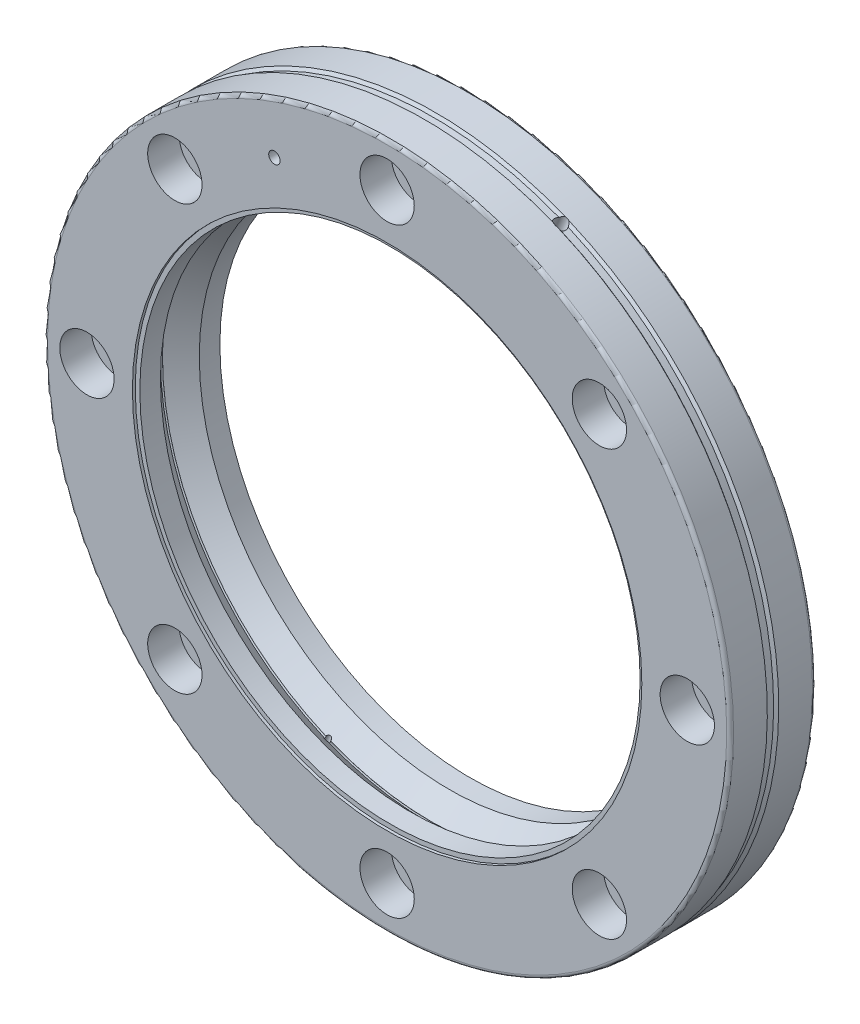
from build123d import *

# Parameters (mm, degrees)
SKETCH_1_R                     = 60
SKETCH_1_R_2                   = 43.75
EXTRUDE_1_DEPTH                = 7.5
FILLET_1_R                     = 0.6
HOLE_WIZARD_M1_6_1_D           = 5.6
HOLE_WIZARD_M1_6_1_CBORE_D     = 9.5
HOLE_WIZARD_M1_6_1_CBORE_DEPTH = 5.5
PATTERN_CIRCULAR_1_COUNT       = 8
CUT_EXTRUDE_START              = 60
SKETCH_7_R                     = 1.05
CUT_EXTRUDE_1_DEPTH            = 5
SKETCH_8_R                     = 0.5
CUT_EXTRUDE_2_DEPTH            = 15
PATTERN_CIRCULAR_2_COUNT       = 2
SKETCH_9_R                     = 44.55
CUT_EXTRUDE_3_DEPTH            = 0.5


with BuildPart() as part:
    # 草图1 → 凸台-拉伸1 (new, symmetric)
    with BuildSketch(Plane.XY):
        Circle(SKETCH_1_R)
        Circle(SKETCH_1_R_2, mode=Mode.SUBTRACT)
    extrude(amount=EXTRUDE_1_DEPTH, both=True)

    # 草图2 → 切除-旋转1 (revolve, cut)
    with BuildSketch(Plane(origin=(0, 0, 0), x_dir=(0, 0, -1), z_dir=(1, 0, 0))):
        with BuildLine():
            Line((-3.535533906, 43.61), (-0.176776695, 46.968757211))
            ThreePointArc((-0.176776695, 46.968757211), (0, 47.395533906), (0.176776695, 46.968757211))
            Line((0.176776695, 46.968757211), (3.535533906, 43.61))
            Line((3.535533906, 43.61), (-3.535533906, 43.61))
        make_face()
        Polygon((-1, 60), (1, 60), (0.6, 59.5), (-0.6, 59.5), align=None)
    revolve(axis=Axis((0, 0, 12.553599724), (0, 0, -1)), mode=Mode.SUBTRACT)

    # 圆角1
    fillet_1_edges = [part.edges().sort_by_distance(p)[0] for p in [
        (-60, 0, -7.5),
        (-60, 0, 7.5),
    ]]
    fillet(fillet_1_edges, radius=FILLET_1_R)

    # M1.6 六角头螺栓的柱形沉头孔1 (through all)
    with Locations(Plane.XY.offset(7.5)):
        with Locations((0, 52.5)):
            hole_wizard_m1_6_1 = CounterBoreHole(HOLE_WIZARD_M1_6_1_D / 2, HOLE_WIZARD_M1_6_1_CBORE_D / 2, HOLE_WIZARD_M1_6_1_CBORE_DEPTH)

    # 阵列(圆周)1: M1.6 六角头螺栓的柱形沉头孔1 ×8 about axis
    pattern_circular_1_axis = Axis((0, 0, 7.5), (0, 0, -1))
    for i in range(1, PATTERN_CIRCULAR_1_COUNT):
        add(hole_wizard_m1_6_1.rotate(pattern_circular_1_axis, i * 360 / PATTERN_CIRCULAR_1_COUNT), mode=Mode.SUBTRACT)

    # 草图7 → 切除-拉伸1 (cut)
    with BuildSketch(Plane(origin=(0, 0, 0), x_dir=(0, 0, -1), z_dir=(0.3826834323650906, 0.9238795325112865, 0)).offset(CUT_EXTRUDE_START)):
        Circle(SKETCH_7_R)
    cut_extrude_1 = extrude(amount=-CUT_EXTRUDE_1_DEPTH, mode=Mode.SUBTRACT)

    # 草图8 → 切除-拉伸2 (cut)
    with BuildSketch(Plane(origin=(21.04758878, 50.813374288, 0), x_dir=(0.9238795325112864, -0.38268343236509067, 0), z_dir=(0.38268343236509067, 0.9238795325112864, 0))):
        Circle(SKETCH_8_R)
    cut_extrude_2 = extrude(amount=-CUT_EXTRUDE_2_DEPTH, mode=Mode.SUBTRACT)

    # 阵列(圆周)2: 切除-拉伸1, 切除-拉伸2 ×2 about axis
    pattern_circular_2_axis = Axis((0, 0, 7.5), (0, 0, -1))
    add([cut_extrude_1.rotate(pattern_circular_2_axis, i * 360 / PATTERN_CIRCULAR_2_COUNT) for i in range(1, PATTERN_CIRCULAR_2_COUNT)], mode=Mode.SUBTRACT)
    add([cut_extrude_2.rotate(pattern_circular_2_axis, i * 360 / PATTERN_CIRCULAR_2_COUNT) for i in range(1, PATTERN_CIRCULAR_2_COUNT)], mode=Mode.SUBTRACT)

    # 草图9 → 切除-拉伸3 (cut)
    with BuildSketch(Plane.XY.offset(7.5)):
        Circle(SKETCH_9_R)
    cut_extrude_3 = extrude(amount=-CUT_EXTRUDE_3_DEPTH, mode=Mode.SUBTRACT)

    # 镜向1: 切除-拉伸3 across plane
    add(cut_extrude_3.mirror(Plane.XY), mode=Mode.SUBTRACT)

    # 切除-拉伸4 cone 1 section (through the dimple's axis) → 切除-拉伸4 (revolve, cut)
    with BuildSketch(Plane(origin=(-19.708196767, 47.579795924, 7.5), x_dir=(0, -1, 0), z_dir=(1, 0, 0))):
        Polygon((0, 0), (1, 0), (0, 50.252823287), align=None)
    revolve(axis=Axis((-19.708196767, 47.579795924, 7.5), (0, 0, -1)), mode=Mode.SUBTRACT)


solid = part.part
